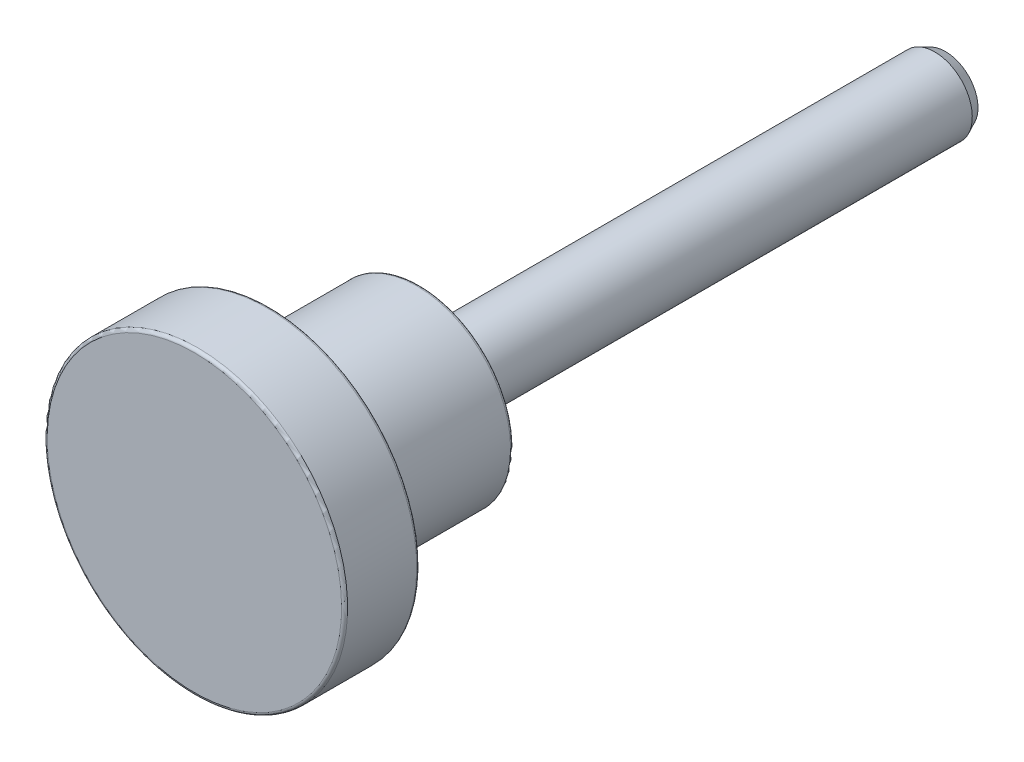
from build123d import *

# Parameters (mm, degrees)
SKETCH1_W = 44.45
SKETCH1_H = 3.175
FILLET1_R = 0.254


with BuildPart() as part:
    # Sketch1 → Revolve1 (revolve)
    with BuildSketch(Plane(origin=(0, 0, 0), x_dir=(0, 0, -1), z_dir=(1, 0, 0))):
        with Locations((0, 1.5875)):
            Rectangle(SKETCH1_W, SKETCH1_H)
    revolve(axis=Axis((0, 0, 8.5598), (0, 0, 1)))

    # Sketch5 → Revolve3 (revolve)
    with BuildSketch(Plane(origin=(0, 0, 0), x_dir=(0, 0, -1), z_dir=(1, 0, 0))):
        Polygon((-22.225, 7.9375), (-34.925, 7.9375), (-34.925, 12.7), (-41.275, 12.7), (-41.275, 0), (-22.225, 0), align=None)
    revolve(axis=Axis((0, 0, 22.225), (0, 0, -1)))

    # Sketch11 → Cut-Revolve4 (revolve, cut)
    with BuildSketch(Plane(origin=(0, 0, 0), x_dir=(0, 0, -1), z_dir=(1, 0, 0))):
        Polygon((21.317857143, 3.175), (22.225, 2.751992339), (22.225, 3.175), align=None)
    revolve(axis=Axis((0, 0, 0), (0, 0, -1)), mode=Mode.SUBTRACT)

    # Fillet1
    fillet1_edges = [part.edges().sort_by_distance(p)[0] for p in [
        (0, -7.9375, 22.225),
        (0, -12.7, 34.925),
        (0, -12.7, 41.275),
    ]]
    fillet(fillet1_edges, radius=FILLET1_R)


solid = part.part
